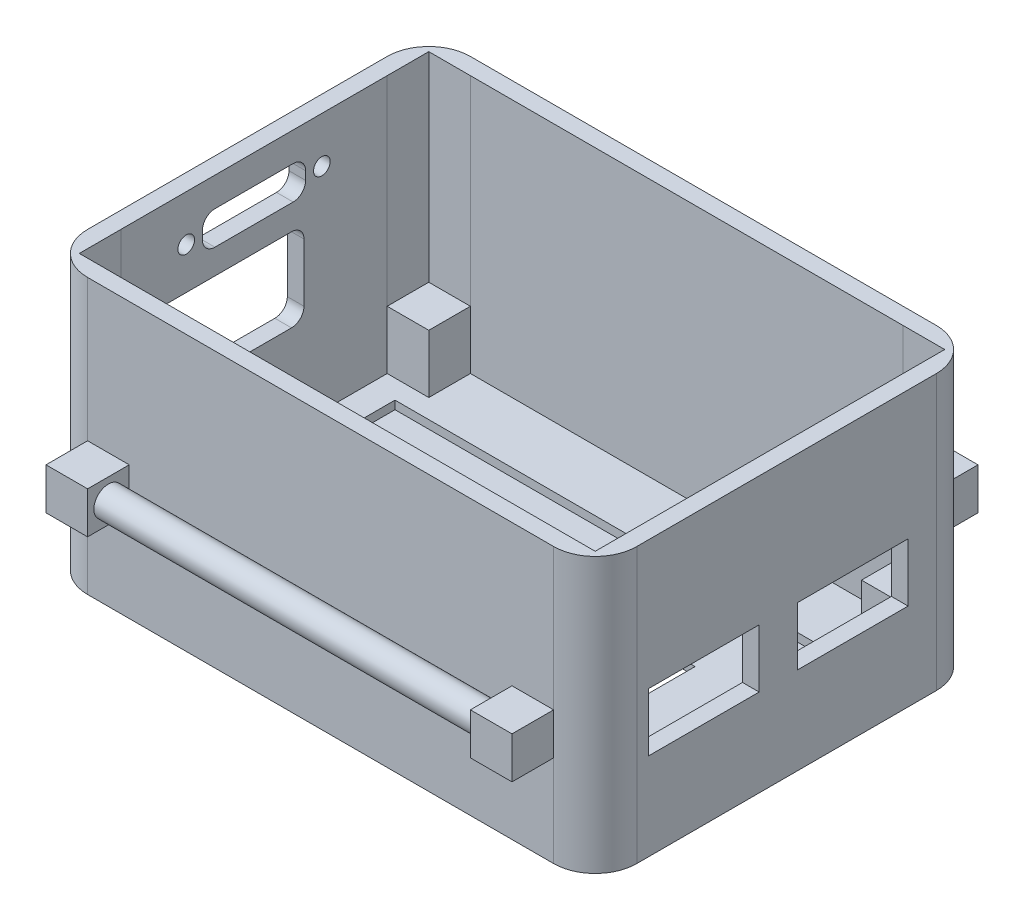
from build123d import *

# Parameters (mm, degrees)
BOSS_EXTRUDE4_DEPTH  = 33
SKETCH1_4_W          = 62
SKETCH1_4_H          = 42
BOSS_EXTRUDE6_DEPTH  = 2
SKETCH1_7_W          = 5
SKETCH1_7_H          = 5
BOSS_EXTRUDE7_DEPTH  = 9
SKETCH5_W            = 10
SKETCH5_H            = 10
CUT_EXTRUDE1_DEPTH   = 87.214847909
SKETCH7_W            = 13.3
SKETCH7_H            = 7
CUT_EXTRUDE3_DEPTH   = 10
SKETCH8_W            = 5
SKETCH8_H            = 5
BOSS_EXTRUDE11_DEPTH = 5
SKETCH9_R            = 1.75
BOSS_EXTRUDE13_DEPTH = 55
SKETCH11_W           = 5
SKETCH11_H           = 5
BOSS_EXTRUDE14_DEPTH = 5
SKETCH12_R           = 1.75
BOSS_EXTRUDE16_DEPTH = 55
CUT_EXTRUDE10_DEPTH  = 10
SKETCH13_4_R         = 1
CUT_EXTRUDE11_DEPTH  = 10
CUT_EXTRUDE12_DEPTH  = 10
SKETCH14_W           = 55.52394705
SKETCH14_H           = 27.402982488
CUT_EXTRUDE13_DEPTH  = 1


with BuildPart() as part:
    # Sketch1 → Boss-Extrude4 (new body)
    with BuildSketch(Plane(origin=(0, 0, 0), x_dir=(1, 0, 0), z_dir=(0, 1, 0))):
        with BuildLine():
            ThreePointArc((0, 5), (1.464466094, 1.464466094), (5, 0))
            Line((5, 0), (61, 0))
            ThreePointArc((61, 0), (64.535533906, 1.464466094), (66, 5))
            Line((66, 5), (66, 41))
            ThreePointArc((66, 41), (64.535533906, 44.535533906), (61, 46))
            Line((61, 46), (5, 46))
            ThreePointArc((5, 46), (1.464466094, 44.535533906), (0, 41))
            Line((0, 41), (0, 5))
        make_face()
        Polygon((64, 44), (64, 39), (64, 7), (64, 2), (59, 2), (7, 2), (2, 2), (2, 7), (2, 39), (2, 44), (7, 44), (59, 44), align=None, mode=Mode.SUBTRACT)
    extrude(amount=BOSS_EXTRUDE4_DEPTH)

    # Sketch1_4 → Boss-Extrude6 (add)
    with BuildSketch(Plane(origin=(0, 0, 0), x_dir=(1, 0, 0), z_dir=(0, 1, 0))):
        with Locations((33, 23)):
            Rectangle(SKETCH1_4_W, SKETCH1_4_H)
    extrude(amount=BOSS_EXTRUDE6_DEPTH)

    # Sketch1_7 → Boss-Extrude7 (add)
    with BuildSketch(Plane(origin=(0, 0, 0), x_dir=(1, 0, 0), z_dir=(0, 1, 0))):
        with Locations((61.5, 41.5)):
            Rectangle(SKETCH1_7_W, SKETCH1_7_H)
        with Locations((61.5, 4.5)):
            Rectangle(SKETCH1_7_W, SKETCH1_7_H)
        with Locations((4.5, 41.5)):
            Rectangle(SKETCH1_7_W, SKETCH1_7_H)
        with Locations((4.5, 4.5)):
            Rectangle(SKETCH1_7_W, SKETCH1_7_H)
    extrude(amount=BOSS_EXTRUDE7_DEPTH)

    # Sketch5 → Cut-Extrude1 (cut, through all)
    with BuildSketch(Plane(origin=(0, 2, 0), x_dir=(1, 0, 0), z_dir=(0, 1, 0))):
        with Locations((45, 23)):
            Rectangle(SKETCH5_W, SKETCH5_H)
    extrude(amount=-CUT_EXTRUDE1_DEPTH, mode=Mode.SUBTRACT)

    # Sketch7 → Cut-Extrude3 (cut)
    with BuildSketch(Plane(origin=(66, 0, 0), x_dir=(0, 0, -1), z_dir=(1, 0, 0))):
        with Locations((13.05, 14)):
            Rectangle(SKETCH7_W, SKETCH7_H)
        with Locations((30.95, 14)):
            Rectangle(SKETCH7_W, SKETCH7_H)
    extrude(amount=-CUT_EXTRUDE3_DEPTH, mode=Mode.SUBTRACT)

    # Sketch8 → Boss-Extrude11 (add)
    with BuildSketch(Plane.XY):
        with Locations((58.5, 13.5)):
            Rectangle(SKETCH8_W, SKETCH8_H)
        with Locations((7.5, 13.5)):
            Rectangle(SKETCH8_W, SKETCH8_H)
    extrude(amount=BOSS_EXTRUDE11_DEPTH)

    # Sketch11 → Boss-Extrude14 (add)
    with BuildSketch(Plane(origin=(0, 0, -46), x_dir=(-1, 0, 0), z_dir=(0, 0, -1))):
        with Locations((-7.5, 13.5)):
            Rectangle(SKETCH11_W, SKETCH11_H)
        with Locations((-58.5, 13.5)):
            Rectangle(SKETCH11_W, SKETCH11_H)
    extrude(amount=BOSS_EXTRUDE14_DEPTH)

    # Sketch12 → Boss-Extrude16 (add)
    with BuildSketch(Plane(origin=(61, 0, 0), x_dir=(0, 0, -1), z_dir=(1, 0, 0))):
        with Locations((48.5, 13.5)):
            Circle(SKETCH12_R)
    extrude(amount=-BOSS_EXTRUDE16_DEPTH)

    # Sketch13 → Cut-Extrude10 (cut)
    with BuildSketch(Plane.ZY):
        with BuildLine():
            Line((-16.8, 27), (-16.8, 28))
            ThreePointArc((-16.8, 28), (-17.239339828, 29.060660172), (-18.3, 29.5))
            Line((-18.3, 29.5), (-27.7, 29.5))
            ThreePointArc((-27.7, 29.5), (-28.760660172, 29.060660172), (-29.2, 28))
            Line((-29.2, 28), (-29.2, 27))
            ThreePointArc((-29.2, 27), (-28.760660172, 25.939339828), (-27.7, 25.5))
            Line((-27.7, 25.5), (-18.3, 25.5))
            ThreePointArc((-18.3, 25.5), (-17.239339828, 25.939339828), (-16.8, 27))
        make_face()
    extrude(amount=-CUT_EXTRUDE10_DEPTH, mode=Mode.SUBTRACT)

    # Sketch13_4 → Cut-Extrude11 (cut)
    with BuildSketch(Plane.ZY):
        with Locations((-31.15, 27.5)):
            Circle(SKETCH13_4_R)
        with Locations((-14.85, 27.5)):
            Circle(SKETCH13_4_R)
    extrude(amount=-CUT_EXTRUDE11_DEPTH, mode=Mode.SUBTRACT)

    # Sketch13_5 → Cut-Extrude12 (cut)
    with BuildSketch(Plane.ZY):
        with BuildLine():
            Line((-27.5, 22.5), (-12.5, 22.5))
            ThreePointArc((-12.5, 22.5), (-11.439339828, 22.060660172), (-11, 21))
            Line((-11, 21), (-11, 14))
            ThreePointArc((-11, 14), (-11.439339828, 12.939339828), (-12.5, 12.5))
            Line((-12.5, 12.5), (-27.5, 12.5))
            ThreePointArc((-27.5, 12.5), (-28.560660172, 12.939339828), (-29, 14))
            Line((-29, 14), (-29, 21))
            ThreePointArc((-29, 21), (-28.560660172, 22.060660172), (-27.5, 22.5))
        make_face()
    extrude(amount=-CUT_EXTRUDE12_DEPTH, mode=Mode.SUBTRACT)

    # Sketch14 → Cut-Extrude13 (cut)
    with BuildSketch(Plane(origin=(0, 2, 0), x_dir=(1, 0, 0), z_dir=(0, 1, 0))):
        with Locations((33, 23)):
            Rectangle(SKETCH14_W, SKETCH14_H)
    extrude(amount=-CUT_EXTRUDE13_DEPTH, mode=Mode.SUBTRACT)


with BuildPart() as body_2:
    # Sketch9 → Boss-Extrude13 (new body)
    with BuildSketch(Plane(origin=(61, 0, 0), x_dir=(0, 0, -1), z_dir=(1, 0, 0))):
        with Locations((-2.5, 13.5)):
            Circle(SKETCH9_R)
    extrude(amount=-BOSS_EXTRUDE13_DEPTH)


solid = Compound([part.part, body_2.part])
